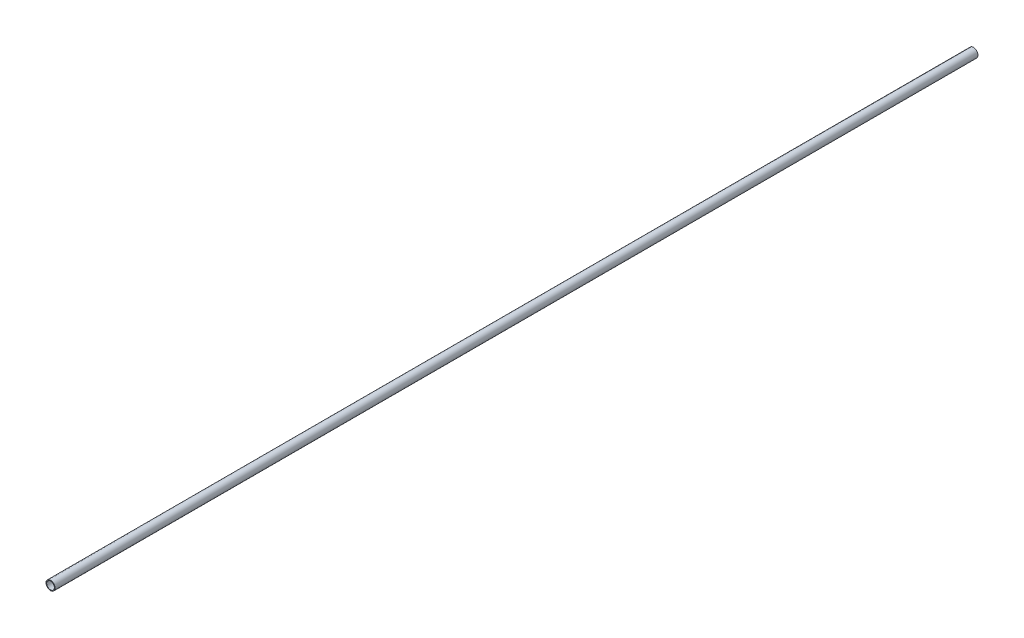
from build123d import *

# Parameters (mm, degrees)
SKETCH1_R           = 5
SKETCH1_R_2         = 4.25
BOSS_EXTRUDE1_DEPTH = 1020


with BuildPart() as part:
    # Sketch1 → Boss-Extrude1 (new body)
    with BuildSketch(Plane.XY):
        Circle(SKETCH1_R)
        Circle(SKETCH1_R_2, mode=Mode.SUBTRACT)
    extrude(amount=BOSS_EXTRUDE1_DEPTH)


solid = part.part
